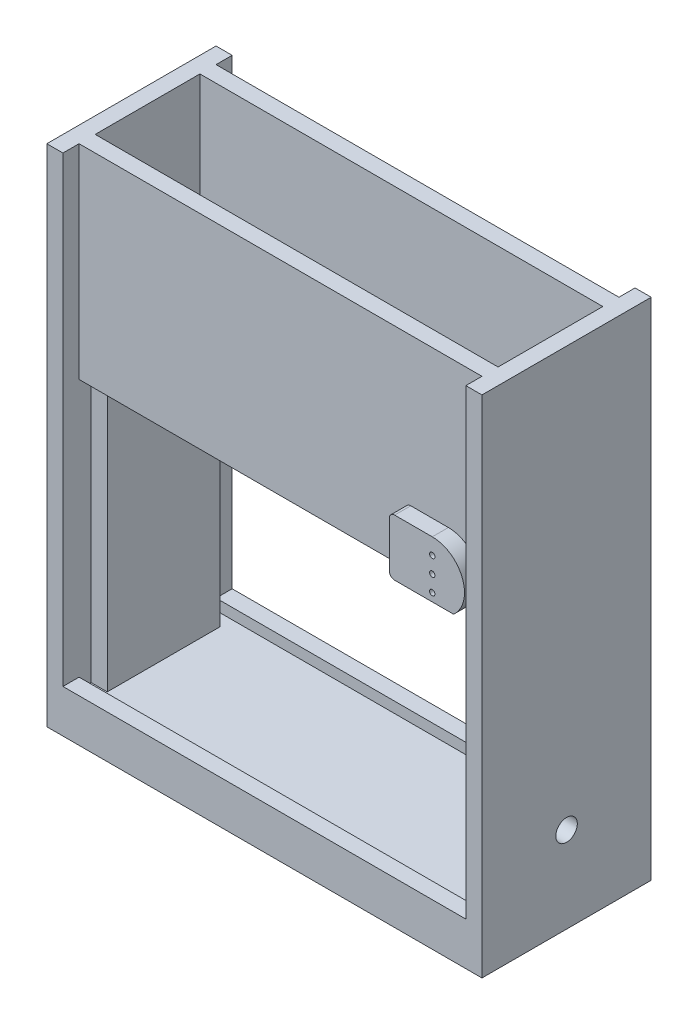
from build123d import *

# Parameters (mm, degrees)
SKETCH1_W            = 150
SKETCH1_H            = 42
BOSS_EXTRUDE1_DEPTH  = 3.2
SKETCH2_W            = 162
SKETCH2_H            = 51
BOSS_EXTRUDE2_DEPTH  = 6
SKETCH3_W            = 6
SKETCH3_H            = 51
BOSS_EXTRUDE3_DEPTH  = 176
BOSS_EXTRUDE4_REACH  = 238.563
SKETCH5_W            = 51
SKETCH5_H            = 6
BOSS_EXTRUDE5_START  = 100
SKETCH1_2_W          = 150
SKETCH1_2_H          = 42
BOSS_EXTRUDE5_DEPTH  = 3.2
SKETCH6_W            = 150
SKETCH6_H            = 6
BOSS_EXTRUDE6_DEPTH  = 70
CUT_EXTRUDE1_REACH   = 142.553
SKETCH7_W            = 9.5
SKETCH7_H            = 39
SKETCH7_R            = 2.75
SKETCH7_3_W          = 6
SKETCH7_3_H          = 39
BOSS_EXTRUDE7_DEPTH  = 54
SKETCH8_W            = 162
SKETCH8_H            = 10
BOSS_EXTRUDE8_DEPTH  = 6
SKETCH9_W            = 150
SKETCH9_H            = 42
CUT_EXTRUDE2_DEPTH   = 3.2
CUT_EXTRUDE3_DEPTH   = 3.2
BOSS_EXTRUDE9_DEPTH  = 6
SKETCH12_W           = 6
SKETCH12_H           = 9.5
BOSS_EXTRUDE10_DEPTH = 6
CUT_EXTRUDE4_REACH   = 235.384
SKETCH13_R           = 4
CUT_EXTRUDE5_REACH   = 202.345
SKETCH14_R           = 1
SKETCH16_W           = 6
SKETCH16_H           = 172
BOSS_EXTRUDE11_DEPTH = 6
BOSS_EXTRUDE15_START = -51
BOSS_EXTRUDE15_DEPTH = 6
SKETCH17_W           = 162
SKETCH17_H           = 63
SKETCH17_W_2         = 150
SKETCH17_H_2         = 56.6
BOSS_EXTRUDE12_DEPTH = 6
SKETCH15_R           = 1
BOSS_EXTRUDE14_DEPTH = 6
FILLET1_R            = 2
FILLET1_OF_MIRROR4_R = 2


with BuildPart() as part:
    # Sketch1 → Boss-Extrude1 (new body)
    with BuildSketch(Plane(origin=(0, 0, 0), x_dir=(1, 0, 0), z_dir=(0, 1, 0))):
        Rectangle(SKETCH1_W, SKETCH1_H)
    extrude(amount=BOSS_EXTRUDE1_DEPTH)

    # Sketch2 → Boss-Extrude2 (add)
    with BuildSketch(Plane.XZ):
        Rectangle(SKETCH2_W, SKETCH2_H)
    extrude(amount=BOSS_EXTRUDE2_DEPTH)

    # Sketch3 → Boss-Extrude3 (add)
    with BuildSketch(Plane(origin=(0, 0, 0), x_dir=(1, 0, 0), z_dir=(0, 1, 0))):
        with Locations((78, 0)):
            Rectangle(SKETCH3_W, SKETCH3_H)
        with Locations((-78, 0)):
            Rectangle(SKETCH3_W, SKETCH3_H)
    extrude(amount=BOSS_EXTRUDE3_DEPTH)

    # Sketch5 → Boss-Extrude4 (add, up to next)
    with BuildSketch(Plane.ZY.offset(-75), mode=Mode.PRIVATE) as boss_extrude4_sk1:
        with Locations((0, 103)):
            Rectangle(SKETCH5_W, SKETCH5_H)
    boss_extrude4_tool1 = extrude(boss_extrude4_sk1.sketch, amount=BOSS_EXTRUDE4_REACH, mode=Mode.PRIVATE) - part.part
    add(boss_extrude4_tool1.solids().sort_by_distance((75, 103, 0))[0])

    # Sketch1_2 → Boss-Extrude5 (add)
    with BuildSketch(Plane(origin=(0, 0, 0), x_dir=(1, 0, 0), z_dir=(0, 1, 0)).offset(BOSS_EXTRUDE5_START)):
        Rectangle(SKETCH1_2_W, SKETCH1_2_H)
    extrude(amount=-BOSS_EXTRUDE5_DEPTH)

    # Sketch6 → Boss-Extrude6 (add)
    with BuildSketch(Plane(origin=(0, 106, 0), x_dir=(1, 0, 0), z_dir=(0, 1, 0))):
        with Locations((0, -22.5)):
            Rectangle(SKETCH6_W, SKETCH6_H)
        with Locations((0, 22.5)):
            Rectangle(SKETCH6_W, SKETCH6_H)
    extrude(amount=BOSS_EXTRUDE6_DEPTH)

    # Sketch7 → Cut-Extrude1 (cut, up to next)
    with BuildSketch(Plane(origin=(0, 106, 0), x_dir=(1, 0, 0), z_dir=(0, 1, 0)), mode=Mode.PRIVATE) as cut_extrude1_sk1:
        with Locations((70.25, 0)):
            Rectangle(SKETCH7_W, SKETCH7_H)
        with Locations((70.25, -14.75)):
            Circle(SKETCH7_R, mode=Mode.SUBTRACT)
        with Locations((70.25, 14.75)):
            Circle(SKETCH7_R, mode=Mode.SUBTRACT)
    cut_extrude1_tool1 = extrude(cut_extrude1_sk1.sketch, amount=-CUT_EXTRUDE1_REACH, mode=Mode.PRIVATE) & part.part
    # Sketch7 → Cut-Extrude1 (cut, up to next)
    with BuildSketch(Plane(origin=(0, 106, 0), x_dir=(1, 0, 0), z_dir=(0, 1, 0)), mode=Mode.PRIVATE) as cut_extrude1_sk2:
        with Locations((70.25, -14.75)):
            Circle(SKETCH7_R)
    cut_extrude1_tool2 = extrude(cut_extrude1_sk2.sketch, amount=-CUT_EXTRUDE1_REACH, mode=Mode.PRIVATE) & part.part
    # Sketch7 → Cut-Extrude1 (cut, up to next)
    with BuildSketch(Plane(origin=(0, 106, 0), x_dir=(1, 0, 0), z_dir=(0, 1, 0)), mode=Mode.PRIVATE) as cut_extrude1_sk3:
        with Locations((70.25, 14.75)):
            Circle(SKETCH7_R)
    cut_extrude1_tool3 = extrude(cut_extrude1_sk3.sketch, amount=-CUT_EXTRUDE1_REACH, mode=Mode.PRIVATE) & part.part
    add(cut_extrude1_tool1.solids().sort_by_distance((70.25, 106, 0))[0], mode=Mode.SUBTRACT)
    add(cut_extrude1_tool2.solids().sort_by_distance((70.25, 106, 14.75))[0], mode=Mode.SUBTRACT)
    add(cut_extrude1_tool3.solids().sort_by_distance((70.25, 106, -14.75))[0], mode=Mode.SUBTRACT)

    # Sketch7_3 → Boss-Extrude7 (add)
    with BuildSketch(Plane(origin=(0, 106, 0), x_dir=(1, 0, 0), z_dir=(0, 1, 0))):
        with Locations((62.5, 0)):
            Rectangle(SKETCH7_3_W, SKETCH7_3_H)
    extrude(amount=BOSS_EXTRUDE7_DEPTH)

    # Sketch8 → Boss-Extrude8 (add)
    with BuildSketch(Plane(origin=(0, 0, -25.5), x_dir=(-1, 0, 0), z_dir=(0, 0, -1))):
        with Locations((0, -1)):
            Rectangle(SKETCH8_W, SKETCH8_H)
    boss_extrude8 = extrude(amount=BOSS_EXTRUDE8_DEPTH)

    # Mirror1: Boss-Extrude8 across plane
    add(boss_extrude8.mirror(Plane.XY))

    # Sketch9 → Cut-Extrude2 (cut)
    with BuildSketch(Plane(origin=(0, 3.2, 0), x_dir=(1, 0, 0), z_dir=(0, 1, 0))):
        Rectangle(SKETCH9_W, SKETCH9_H)
    extrude(amount=-CUT_EXTRUDE2_DEPTH, mode=Mode.SUBTRACT)

    # Sketch10 → Cut-Extrude3 (cut)
    with BuildSketch(Plane.XZ.offset(-96.8)):
        Polygon((-75, -21), (75, -21), (75, -19.5), (65.5, -19.5), (65.5, 19.5), (75, 19.5), (75, 21), (-75, 21), align=None)
    extrude(amount=-CUT_EXTRUDE3_DEPTH, mode=Mode.SUBTRACT)

    # Sketch11 → Boss-Extrude9 (add)
    with BuildSketch(Plane.ZY.offset(-75)):
        Polygon((10, 93.5), (-21, 93.5), (-21, 0), (21, 0), (21, 100), (10, 100), align=None)
    boss_extrude9 = extrude(amount=BOSS_EXTRUDE9_DEPTH)

    # Mirror2: Boss-Extrude9 across plane
    add(boss_extrude9.mirror(Plane(origin=(0, 0, 0), x_dir=(0, 0, 1), z_dir=(1, 0, 0))))

    # Sketch12 → Boss-Extrude10 (add)
    with BuildSketch(Plane(origin=(0, 100, 0), x_dir=(1, 0, 0), z_dir=(0, 1, 0))):
        with Locations((72, -14.75)):
            Rectangle(SKETCH12_W, SKETCH12_H)
    extrude(amount=BOSS_EXTRUDE10_DEPTH)

    # Sketch13 → Cut-Extrude4 (cut, up to next)
    with BuildSketch(Plane.ZY.offset(-69), mode=Mode.PRIVATE) as cut_extrude4_sk1:
        with Locations((0, 20)):
            Circle(SKETCH13_R)
    cut_extrude4_tool1 = extrude(cut_extrude4_sk1.sketch, amount=-CUT_EXTRUDE4_REACH, mode=Mode.PRIVATE) & part.part
    add(cut_extrude4_tool1.solids().sort_by_distance((69, 20, 0))[0], mode=Mode.SUBTRACT)

    # Sketch14 → Cut-Extrude5 (cut, up to next)
    with BuildSketch(Plane.XY.offset(-19.5), mode=Mode.PRIVATE) as cut_extrude5_sk1:
        with Locations((62.5, 103)):
            Circle(SKETCH14_R)
    cut_extrude5_tool1 = extrude(cut_extrude5_sk1.sketch, amount=-CUT_EXTRUDE5_REACH, mode=Mode.PRIVATE) & part.part
    # Sketch14 → Cut-Extrude5 (cut, up to next)
    with BuildSketch(Plane.XY.offset(-19.5), mode=Mode.PRIVATE) as cut_extrude5_sk2:
        with Locations((62.5, 109)):
            Circle(SKETCH14_R)
    cut_extrude5_tool2 = extrude(cut_extrude5_sk2.sketch, amount=-CUT_EXTRUDE5_REACH, mode=Mode.PRIVATE) & part.part
    # Sketch14 → Cut-Extrude5 (cut, up to next)
    with BuildSketch(Plane.XY.offset(-19.5), mode=Mode.PRIVATE) as cut_extrude5_sk3:
        with Locations((62.5, 115)):
            Circle(SKETCH14_R)
    cut_extrude5_tool3 = extrude(cut_extrude5_sk3.sketch, amount=-CUT_EXTRUDE5_REACH, mode=Mode.PRIVATE) & part.part
    add(cut_extrude5_tool1.solids().sort_by_distance((62.5, 103, -19.5))[0], mode=Mode.SUBTRACT)
    add(cut_extrude5_tool2.solids().sort_by_distance((62.5, 109, -19.5))[0], mode=Mode.SUBTRACT)
    add(cut_extrude5_tool3.solids().sort_by_distance((62.5, 115, -19.5))[0], mode=Mode.SUBTRACT)

    # Sketch16 → Boss-Extrude11 (add)
    with BuildSketch(Plane(origin=(0, 0, -25.5), x_dir=(-1, 0, 0), z_dir=(0, 0, -1))):
        with Locations((78, 90)):
            Rectangle(SKETCH16_W, SKETCH16_H)
        with Locations((-78, 90)):
            Rectangle(SKETCH16_W, SKETCH16_H)
    extrude(amount=BOSS_EXTRUDE11_DEPTH)

    # Sketch16_2 → Boss-Extrude15 (add)
    with BuildSketch(Plane(origin=(0, 0, -25.5), x_dir=(-1, 0, 0), z_dir=(0, 0, -1)).offset(BOSS_EXTRUDE15_START)):
        Polygon((75, 100), (75, 4), (81, 4), (81, 176), (75, 176), align=None)
        Polygon((-75, 4), (-75, 100), (-75, 176), (-81, 176), (-81, 4), align=None)
    extrude(amount=-BOSS_EXTRUDE15_DEPTH)

    # Sketch17 → Boss-Extrude12 (add)
    with BuildSketch(Plane.XZ.offset(6)):
        Rectangle(SKETCH17_W, SKETCH17_H)
        Rectangle(SKETCH17_W_2, SKETCH17_H_2, mode=Mode.SUBTRACT)
    extrude(amount=BOSS_EXTRUDE12_DEPTH)

    # Sketch15 → Boss-Extrude14 (add)
    with BuildSketch(Plane(origin=(0, 0, -25.5), x_dir=(-1, 0, 0), z_dir=(0, 0, -1))):
        with BuildLine():
            ThreePointArc((-62.5, 121), (-51.27502784, 113.242640687), (-54.562746067, 100))
            Line((-54.562746067, 100), (-46.5, 100))
            Line((-46.5, 100), (-46.5, 121))
            Line((-46.5, 121), (-62.5, 121))
        make_face()
        with BuildLine():
            ThreePointArc((-62.5, 121), (-73.72497216, 113.242640687), (-70.437253933, 100))
            Line((-70.437253933, 100), (-54.562746067, 100))
            ThreePointArc((-54.562746067, 100), (-51.27502784, 113.242640687), (-62.5, 121))
        make_face()
        with Locations(Location((-62.5, 103, 0), (0, 0, 180))):
            Circle(SKETCH15_R, mode=Mode.SUBTRACT)
        with Locations(Location((-62.5, 109, 0), (0, 0, 180))):
            Circle(SKETCH15_R, mode=Mode.SUBTRACT)
        with Locations(Location((-62.5, 115, 0), (0, 0, 180))):
            Circle(SKETCH15_R, mode=Mode.SUBTRACT)
    boss_extrude14 = extrude(amount=BOSS_EXTRUDE14_DEPTH)

    # Fillet1
    fillet1_edges = [part.edges().sort_by_distance(p)[0] for p in [
        (46.5, 121, -28.5),
        (46.5, 100, -28.5),
    ]]
    fillet(fillet1_edges, radius=FILLET1_R)

    # Mirror4: Boss-Extrude14 across plane
    add(boss_extrude14.mirror(Plane.XY))

    # Fillet1 of Mirror4
    fillet1_of_mirror4_edges = [part.edges().sort_by_distance(p)[0] for p in [
        (46.5, 121, 28.5),
        (46.5, 100, 28.5),
    ]]
    fillet(fillet1_of_mirror4_edges, radius=FILLET1_OF_MIRROR4_R)


solid = part.part
